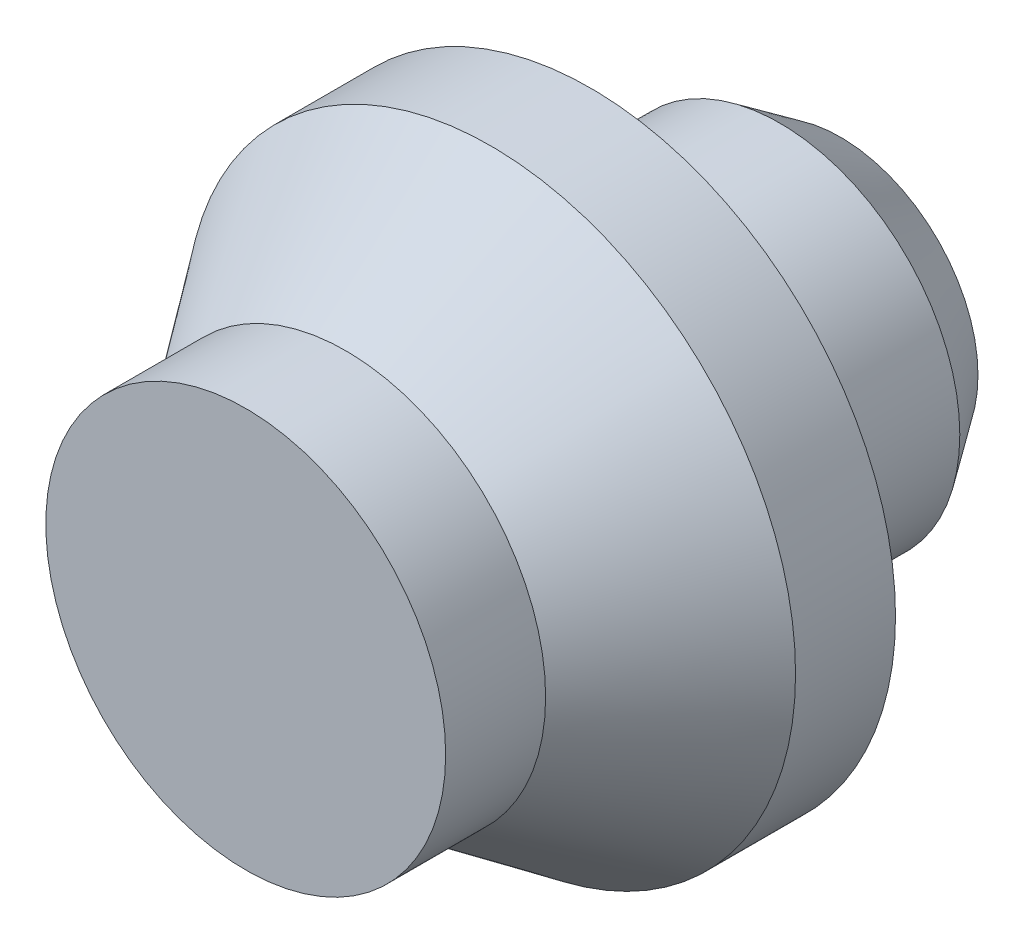
from build123d import *


with BuildPart() as part:
    # Sketch1 → Revolve1 (revolve)
    with BuildSketch(Plane(origin=(0, 0, 0), x_dir=(1, 0, 0), z_dir=(0, 1, 0))):
        Polygon((0, 0), (0, 11.9), (2.75, 11.9), (3.6, 10.686074194), (3.6, 6.9), (6.1, 6.9), (6.1, 4.9), (4, 2), (4, 0), align=None)
    revolve(axis=Axis((0, 0, 0), (0, 0, -1)))


solid = part.part
